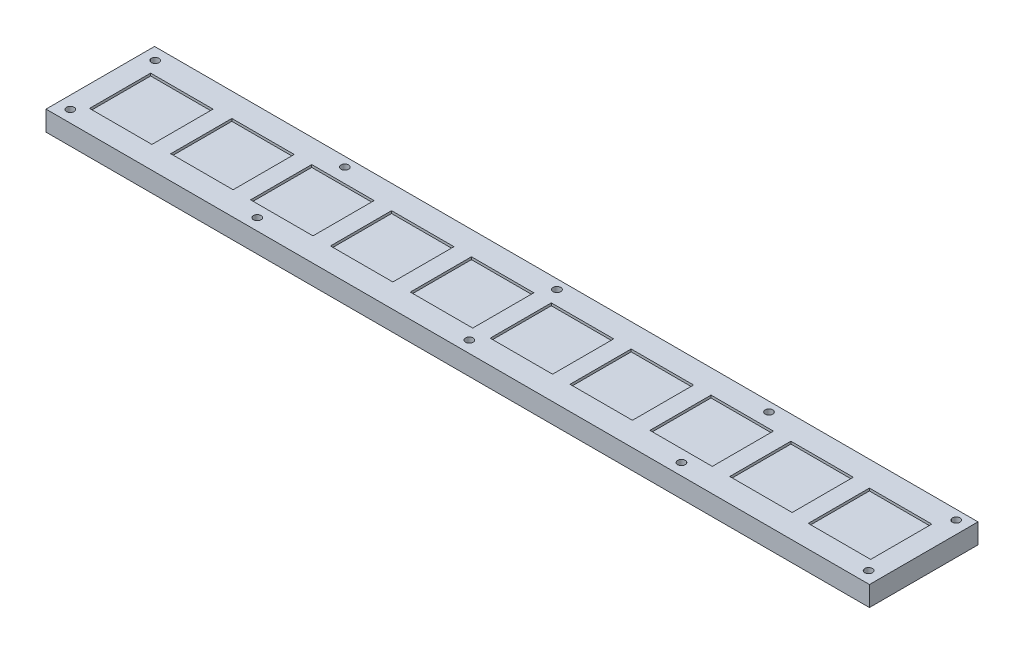
from build123d import *

# Parameters (mm, degrees)
SKETCH1_W                        = 330
SKETCH1_H                        = 43.5
BOSS_EXTRUDE1_DEPTH              = 8
SKETCH6_W                        = 25.004721381
SKETCH6_H                        = 24.5
SKETCH6_W_2                      = 25.004721382
CUT_EXTRUDE1_DEPTH               = 1
TAPPED_HOLE_FOR_4_40_HELICOIL2_D = 3.048


with BuildPart() as part:
    # Sketch1 → Boss-Extrude1 (new body)
    with BuildSketch(Plane(origin=(0, 0, 0), x_dir=(1, 0, 0), z_dir=(0, 1, 0))):
        with Locations((-165, 21.75)):
            Rectangle(SKETCH1_W, SKETCH1_H)
    extrude(amount=BOSS_EXTRUDE1_DEPTH)

    # Sketch6 → Cut-Extrude1 (cut)
    with BuildSketch(Plane(origin=(0, 8, 0), x_dir=(1, 0, 0), z_dir=(0, 1, 0))):
        with Locations((-213.007082072, 21.75)):
            Rectangle(SKETCH6_W, SKETCH6_H)
        with Locations((-181.002360691, 21.75)):
            Rectangle(SKETCH6_W_2, SKETCH6_H)
        with Locations((-245.011803454, 21.75)):
            Rectangle(SKETCH6_W_2, SKETCH6_H)
        with Locations((-277.016524836, 21.75)):
            Rectangle(SKETCH6_W_2, SKETCH6_H)
        with Locations((-309.021246217, 21.209761144)):
            Rectangle(SKETCH6_W, SKETCH6_H)
        with Locations((-148.997639309, 21.75)):
            Rectangle(SKETCH6_W_2, SKETCH6_H)
        with Locations((-116.992917928, 21.75)):
            Rectangle(SKETCH6_W, SKETCH6_H)
        with Locations((-84.988196546, 21.75)):
            Rectangle(SKETCH6_W_2, SKETCH6_H)
        with Locations((-52.983475164, 21.75)):
            Rectangle(SKETCH6_W_2, SKETCH6_H)
        with Locations((-20.978753783, 21.209761144)):
            Rectangle(SKETCH6_W, SKETCH6_H)
    extrude(amount=-CUT_EXTRUDE1_DEPTH, mode=Mode.SUBTRACT)

    # Tapped Hole for #4-40 Helicoil2 (through all)
    with Locations(Plane(origin=(0, 8, 0), x_dir=(1, 0, 0), z_dir=(0, 1, 0))):
        with Locations((-165, 39.745256998), (-165, 4.663980245), (-250, 4.663980245), (-325, 4.75), (-325, 38.75), (-250, 39.745256998), (-80, 39.745256998), (-80, 4.663980245), (-5, 4.663980245), (-5, 39.745256998)):
            Hole(TAPPED_HOLE_FOR_4_40_HELICOIL2_D / 2)


solid = part.part
